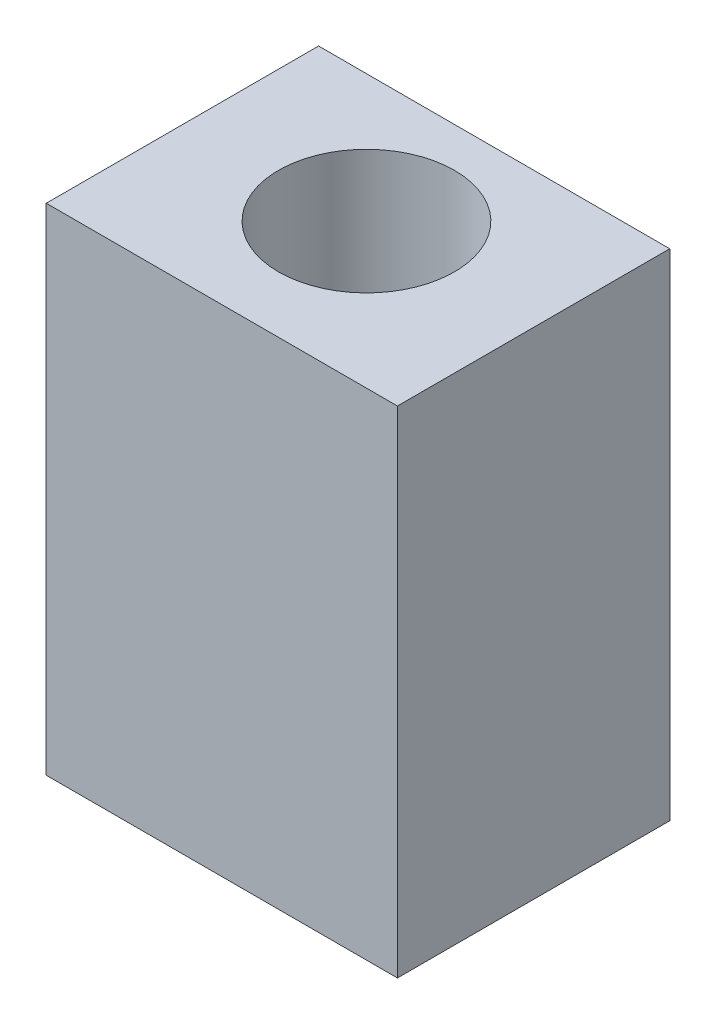
from build123d import *

# Parameters (mm, degrees)
SKETCH1_W                  = 41.91
SKETCH1_H                  = 32.5
BOSS_EXTRUDE1_DEPTH        = 59.1185
SKETCH2_R                  = 10.5
CUT_EXTRUDE1_DEPTH         = 60.1185
F_10_32_TAPPED_HOLE1_D     = 4.0386
F_10_32_TAPPED_HOLE1_DEPTH = 9.906
F_10_32_TAPPED_HOLE1_TIP   = 1.213317848


with BuildPart() as part:
    # Sketch1 → Boss-Extrude1 (new body)
    with BuildSketch(Plane(origin=(0, 0, 0), x_dir=(1, 0, 0), z_dir=(0, 1, 0))):
        Rectangle(SKETCH1_W, SKETCH1_H)
    extrude(amount=BOSS_EXTRUDE1_DEPTH)

    # Sketch2 → Cut-Extrude1 (cut, through all)
    with BuildSketch(Plane(origin=(0, 59.1185, 0), x_dir=(1, 0, 0), z_dir=(0, 1, 0))):
        with Locations((0, 1.01)):
            Circle(SKETCH2_R)
    extrude(amount=-CUT_EXTRUDE1_DEPTH, mode=Mode.SUBTRACT)

    # #10-32 Tapped Hole1
    with Locations(Plane(origin=(0, 0, -16.25), x_dir=(-1, 0, 0), z_dir=(0, 0, -1))):
        with Locations((-14.986, 14.31925), (14.986, 14.31925), (14.986, 44.79925), (-14.986, 44.79925)):
            Hole(F_10_32_TAPPED_HOLE1_D / 2, depth=F_10_32_TAPPED_HOLE1_DEPTH)
            with Locations((0, 0, -(F_10_32_TAPPED_HOLE1_DEPTH + F_10_32_TAPPED_HOLE1_TIP / 2))):  # 118° drill point
                Cone(0, F_10_32_TAPPED_HOLE1_D / 2, F_10_32_TAPPED_HOLE1_TIP, mode=Mode.SUBTRACT)


solid = part.part
